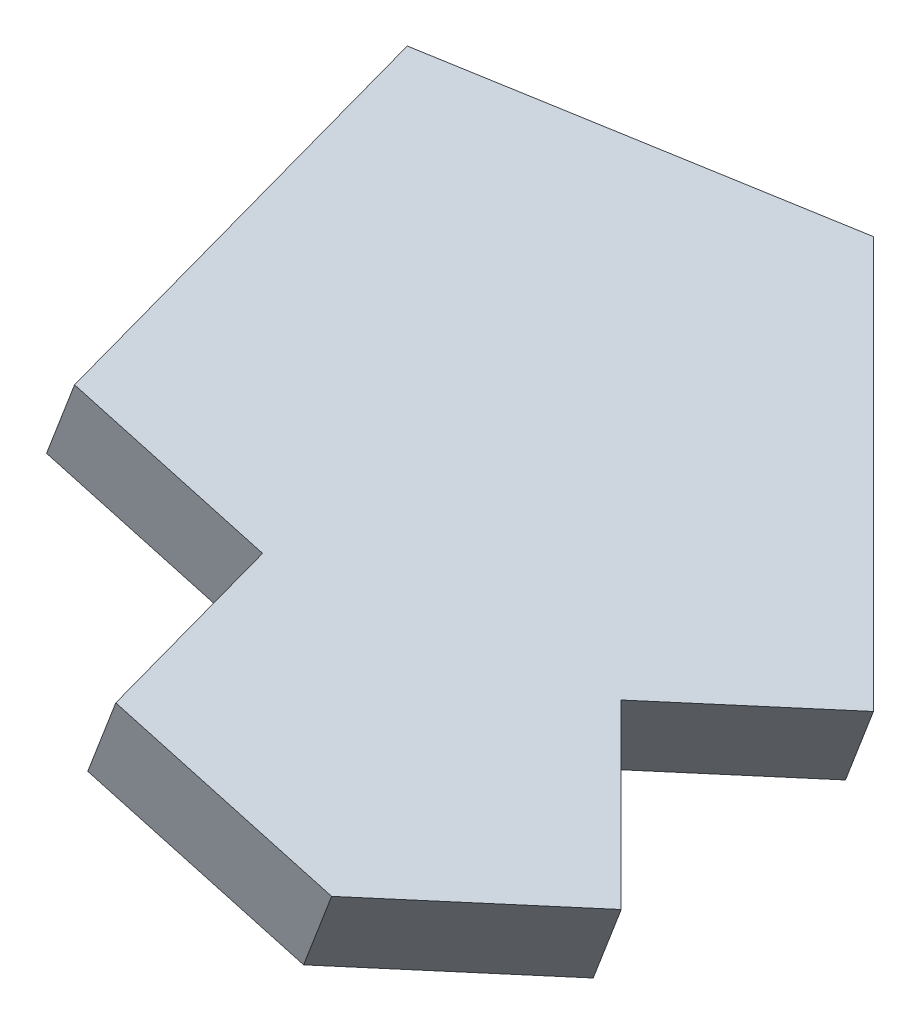
from build123d import *

# Parameters (mm, degrees)
BOSS_EXTRUDE1_DEPTH = 2.8


with BuildPart() as part:
    # Sketch2 → Boss-Extrude1 (new body)
    with BuildSketch(Plane(origin=(-12.267505543, -19.849240926, -7.581735383), x_dir=(0.866025404, -0.467086179, -0.178411045), z_dir=(0.5, 0.809016994, 0.309016994))):
        Polygon((60.719896775, -106.436470809), (57.282942583, -106.436470809), (57.282942583, -99.636470809), (60.459128604, -98.423275703), (63.635314624, -97.210080598), (68.168647957, -102.278501347), (65.606893554, -104.569804142), (67.606893554, -106.805872119), (65.519896775, -108.672538786), (64.665794809, -109.436470809), (63.519896775, -109.436470809), (60.719896775, -109.436470809), align=None)
    extrude(amount=BOSS_EXTRUDE1_DEPTH)


solid = part.part
